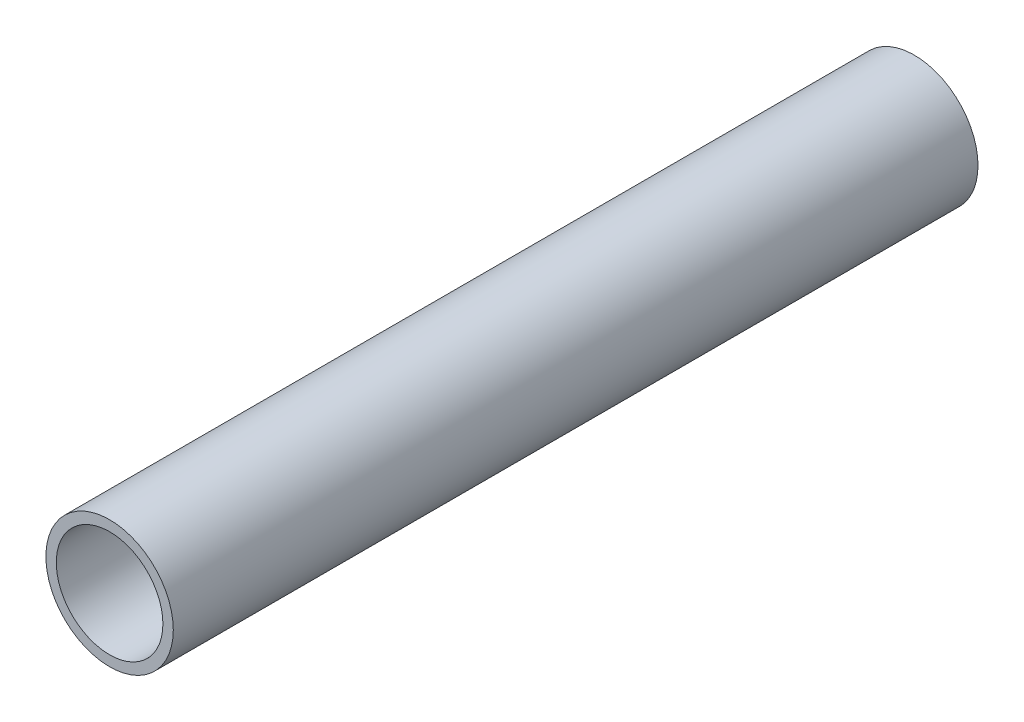
from build123d import *

# Parameters (mm, degrees)
SKETCH1_R           = 24.13
SKETCH1_R_2         = 20.193
BOSS_EXTRUDE1_DEPTH = 304.8


with BuildPart() as part:
    # Sketch1 → Boss-Extrude1 (new body)
    with BuildSketch(Plane.XY):
        Circle(SKETCH1_R)
        Circle(SKETCH1_R_2, mode=Mode.SUBTRACT)
    extrude(amount=BOSS_EXTRUDE1_DEPTH)


solid = part.part
